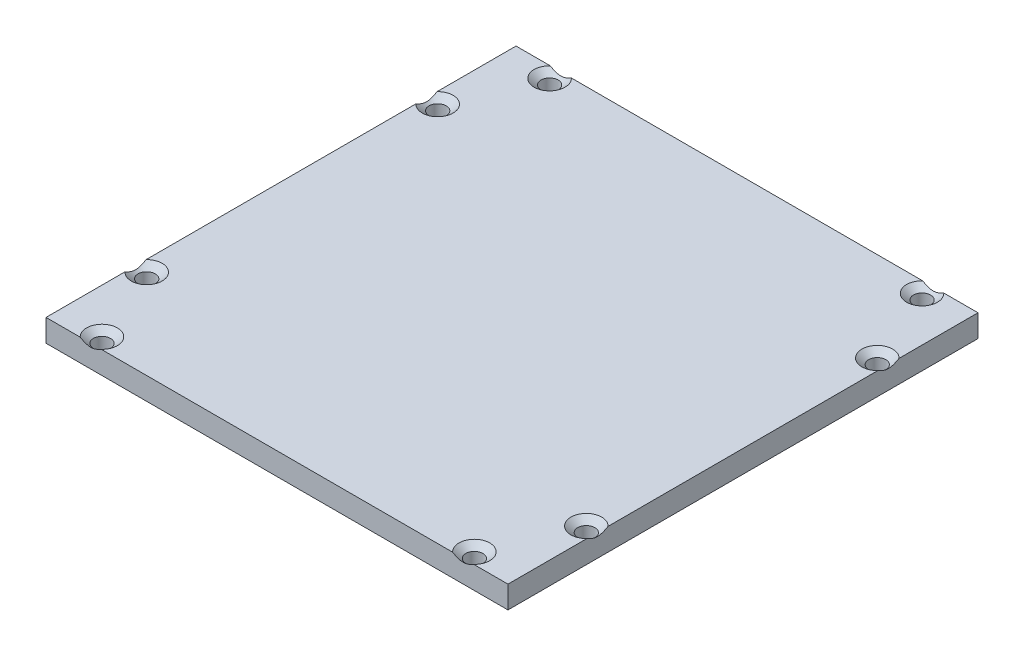
from build123d import *

# Parameters (mm, degrees)
SKETCH1_W                                         = 65.532
SKETCH1_H                                         = 66.675
EXTRUDE1_DEPTH                                    = 3.175
CSK_FOR_2_FLAT_HEAD_MACHINE_SCREW_100_D           = 2.4384
CSK_FOR_2_FLAT_HEAD_MACHINE_SCREW_100_CSINK_D     = 4.3688
CSK_FOR_2_FLAT_HEAD_MACHINE_SCREW_100_CSINK_ANGLE = 100


with BuildPart() as part:
    # Sketch1 → Extrude1 (new body)
    with BuildSketch(Plane(origin=(0, 0, 0), x_dir=(1, 0, 0), z_dir=(0, 1, 0))):
        Rectangle(SKETCH1_W, SKETCH1_H)
    extrude(amount=EXTRUDE1_DEPTH)

    # CSK for #2 Flat Head Machine Screw (100)1 (through all)
    with Locations(Plane(origin=(-26.416, 3.175, 31.75), x_dir=(0, 0, 1), z_dir=(0, 1, 0))):
        with Locations((0, 0), (0, 52.832), (-63.5, 52.832), (-63.5, 0), (-52.3875, -4.7625), (-11.1125, -4.7625), (-52.3875, 57.5945), (-11.1125, 57.5945)):
            CounterSinkHole(CSK_FOR_2_FLAT_HEAD_MACHINE_SCREW_100_D / 2, CSK_FOR_2_FLAT_HEAD_MACHINE_SCREW_100_CSINK_D / 2, counter_sink_angle=CSK_FOR_2_FLAT_HEAD_MACHINE_SCREW_100_CSINK_ANGLE)


solid = part.part
